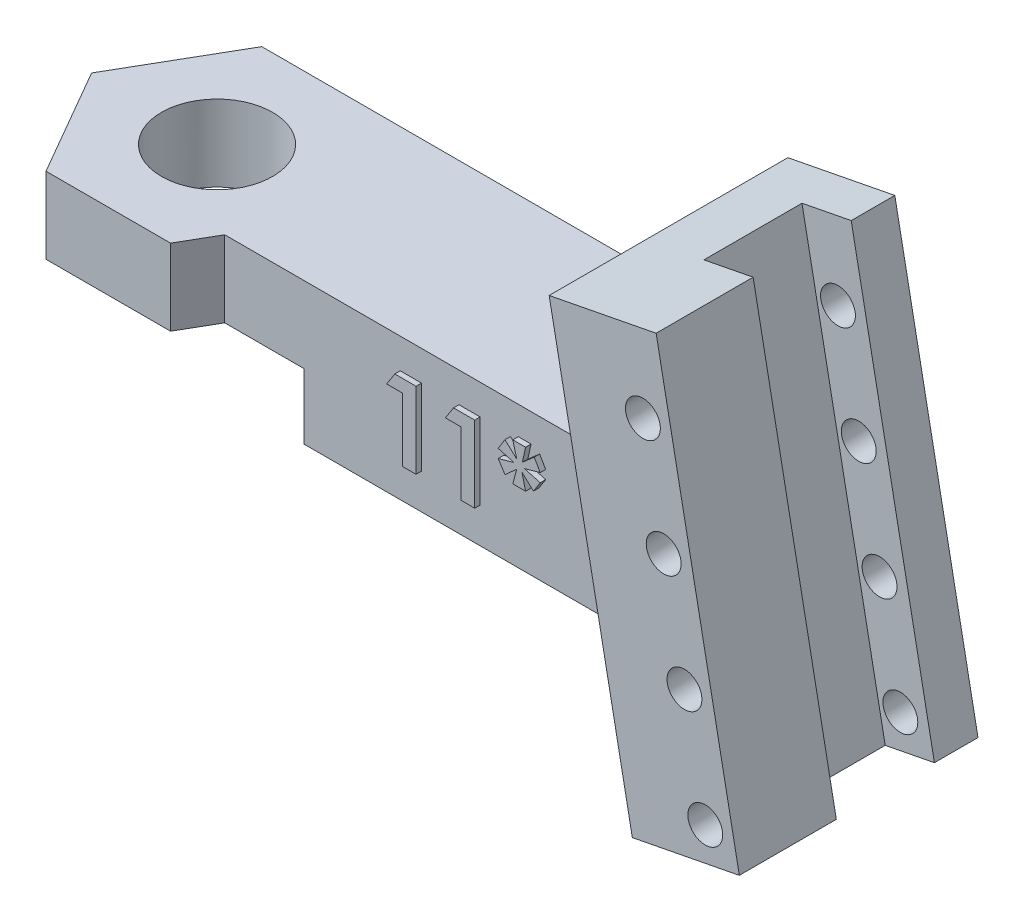
from build123d import *

# Parameters (mm, degrees)
SKETCH1_W                = 25
SKETCH1_H                = 6.75
BOSS_EXTRUDE1_DEPTH      = 6.5
BOSS_EXTRUDE4_DEPTH      = 6.5
BOSS_EXTRUDE3_DEPTH      = 6
BOSS_EXTRUDE3_DEPTH_BACK = 4.95
SKETCH4_W                = 2.3
SKETCH4_H                = 4.5
CUT_EXTRUDE1_DEPTH       = 23
SKETCH6_R                = 2.55
CUT_EXTRUDE2_DEPTH       = 10
BOSS_EXTRUDE5_DEPTH      = 1.575
CUT_EXTRUDE3_DEPTH       = 3
SKETCH9_R                = 0.8
CUT_EXTRUDE4_DEPTH       = 10.95
BOSS_EXTRUDE6_DEPTH      = 0.25


with BuildPart() as part:
    # Sketch1 → Boss-Extrude1 (new body)
    with BuildSketch(Plane(origin=(0, 0, 0), x_dir=(1, 0, 0), z_dir=(0, 1, 0))):
        with Locations((12.5, -3.375)):
            Rectangle(SKETCH1_W, SKETCH1_H)
    extrude(amount=BOSS_EXTRUDE1_DEPTH)

    # Sketch5 → Boss-Extrude4 (add)
    with BuildSketch(Plane(origin=(0, 6.5, 0), x_dir=(1, 0, 0), z_dir=(0, 1, 0))):
        Polygon((-5.715767665, -3.375), (-2.857883832, -8.325), (2.857883832, -8.325), (5.715767665, -3.375), (2.857883832, 1.575), (-2.857883832, 1.575), align=None)
    extrude(amount=-BOSS_EXTRUDE4_DEPTH)

    # Sketch3 → Boss-Extrude3 (add, two sides)
    with BuildSketch(Plane.XY.offset(3.375)) as boss_extrude3_sk:
        Polygon((21.275684175, 14.155521181), (26.183820092, 15.109566157), (30, -4.522977512), (25.091864083, -5.477022488), align=None)
    extrude(amount=BOSS_EXTRUDE3_DEPTH)
    extrude(boss_extrude3_sk.sketch, amount=-BOSS_EXTRUDE3_DEPTH_BACK)

    # Sketch4 → Cut-Extrude1 (cut)
    with BuildSketch(Plane(origin=(-1.876769127, 9.65514015, 0), x_dir=(0.981627183, 0.190808995, 0), z_dir=(-0.190808995, 0.981627183, 0))):
        with Locations((27.435790708, -2.675)):
            Rectangle(SKETCH4_W, SKETCH4_H)
    extrude(amount=-CUT_EXTRUDE1_DEPTH, mode=Mode.SUBTRACT)

    # Sketch6 → Cut-Extrude2 (cut)
    with BuildSketch(Plane(origin=(0, 6.5, 0), x_dir=(1, 0, 0), z_dir=(0, 1, 0))):
        with Locations((0, -3.335615973)):
            Circle(SKETCH6_R)
    extrude(amount=-CUT_EXTRUDE2_DEPTH, mode=Mode.SUBTRACT)

    # Sketch7 → Boss-Extrude5 (add)
    with BuildSketch(Plane(origin=(0, 0, -1.575), x_dir=(-1, 0, 0), z_dir=(0, 0, -1))):
        Polygon((-2.857883832, 0), (-24.027238758, 0), (-25.091864083, -5.477022488), (-30, -4.522977512), (-26.183820092, 15.109566157), (-21.275684175, 14.155521181), (-22.763766749, 6.5), (-2.857883832, 6.5), align=None)
    extrude(amount=-BOSS_EXTRUDE5_DEPTH)

    # Sketch8 → Cut-Extrude3 (cut)
    with BuildSketch(Plane(origin=(0, 0, 0), x_dir=(-1, 0, 0), z_dir=(0, -1, 0))):
        Polygon((-4.67653718, -11.475), (4.67653718, -11.475), (9.353074361, -3.375), (4.67653718, 4.725), (-4.67653718, 4.725), (-9.353074361, -3.375), align=None)
    extrude(amount=-CUT_EXTRUDE3_DEPTH, mode=Mode.SUBTRACT)

    # Sketch9 → Cut-Extrude4 (cut)
    with BuildSketch(Plane(origin=(0, 0, -1.575), x_dir=(-1, 0, 0), z_dir=(0, 0, -1))):
        with Locations((-28.437671168, -3.29858843)):
            Circle(SKETCH9_R)
        with Locations((-27.483626192, 1.609547487)):
            Circle(SKETCH9_R)
        with Locations((-26.529581215, 6.517683404)):
            Circle(SKETCH9_R)
        with Locations((-25.575536238, 11.425819321)):
            Circle(SKETCH9_R)
    extrude(amount=-CUT_EXTRUDE4_DEPTH, mode=Mode.SUBTRACT)

    # Sketch10 → Boss-Extrude6 (add)
    with BuildSketch(Plane.XY.offset(6.75)):
        Polygon((11.821517388, 5.121255448), (12.792571074, 5.121255448), (12.792571074, 1.621255448), (12.164365946, 1.621255448), (12.164365946, 4.537922115), (11.446417228, 4.537922115), align=None)
        Polygon((14.513825081, 5.121255448), (15.484878766, 5.121255448), (15.484878766, 1.621255448), (14.856673638, 1.621255448), (14.856673638, 4.537922115), (14.13872492, 4.537922115), align=None)
        Polygon((17.234878766, 5.210999038), (17.8182121, 5.210999038), (17.672378766, 4.537922115), (18.215748157, 5.013983814), (18.491289023, 4.537922115), (17.773340305, 4.335999038), (18.491289023, 4.134075961), (18.180692068, 3.647497435), (17.6541496, 4.134075961), (17.8182121, 3.460999038), (17.234878766, 3.460999038), (17.412262581, 4.134075961), (16.873801042, 3.647497435), (16.561801843, 4.134075961), (17.279750561, 4.335999038), (16.561801843, 4.537922115), (16.873801042, 5.036419711), (17.412262581, 4.537922115), align=None)
    extrude(amount=BOSS_EXTRUDE6_DEPTH)


solid = part.part
